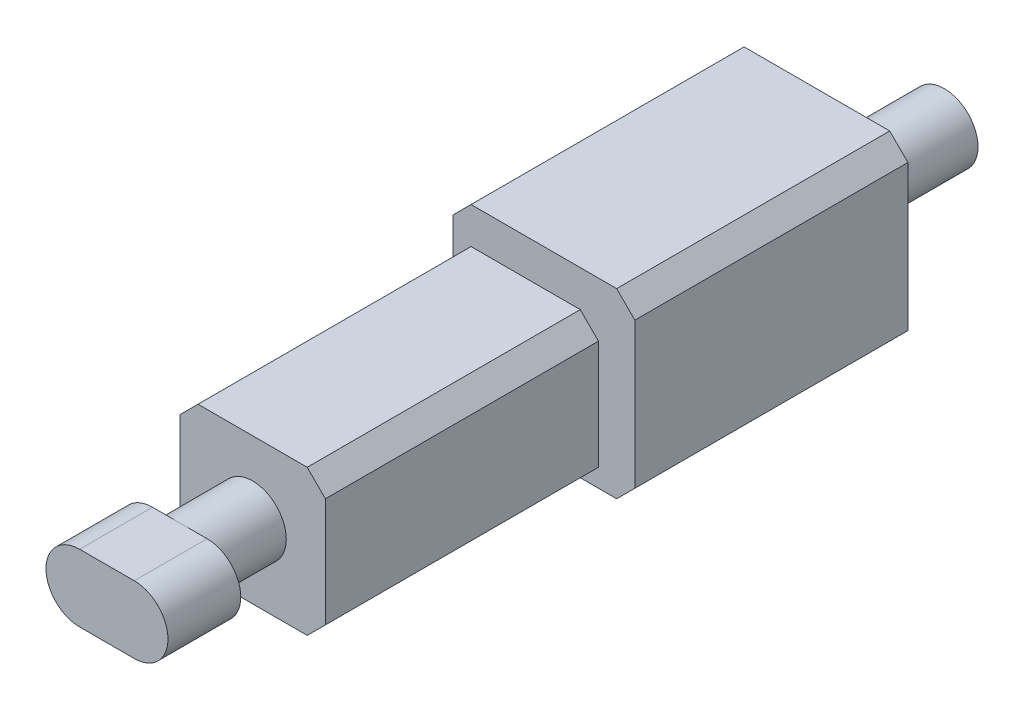
from build123d import *

# Parameters (mm, degrees)
SKETCH1_W           = 4
SKETCH1_H           = 15
BOSS_EXTRUDE1_DEPTH = 4
SKETCH2_R           = 0.925
BOSS_EXTRUDE2_DEPTH = 2
BOSS_EXTRUDE3_DEPTH = 2
SKETCH6_W           = 5
SKETCH6_H           = 5
BOSS_EXTRUDE5_DEPTH = 7.5
SKETCH7_R           = 0.925
BOSS_EXTRUDE6_DEPTH = 18
CHAMFER1_SIZE       = 0.5


with BuildPart() as part:
    # Sketch1 → Boss-Extrude1 (new body)
    with BuildSketch(Plane(origin=(0, 0, 0), x_dir=(1, 0, 0), z_dir=(0, 1, 0))):
        Rectangle(SKETCH1_W, SKETCH1_H)
    extrude(amount=BOSS_EXTRUDE1_DEPTH)

    # Sketch2 → Boss-Extrude2 (add)
    with BuildSketch(Plane.XY.offset(7.5)):
        with Locations((0, 2)):
            Circle(SKETCH2_R)
    extrude(amount=BOSS_EXTRUDE2_DEPTH)

    # Sketch3 → Boss-Extrude3 (add)
    with BuildSketch(Plane.XY.offset(9.5)):
        with BuildLine():
            Line((-0.75, 2.925), (0.75, 2.925))
            ThreePointArc((0.75, 2.925), (1.675, 2), (0.75, 1.075))
            Line((0.75, 1.075), (-0.75, 1.075))
            ThreePointArc((-0.75, 1.075), (-1.675, 2), (-0.75, 2.925))
        make_face()
    extrude(amount=BOSS_EXTRUDE3_DEPTH)

    # Sketch6 → Boss-Extrude5 (add)
    with BuildSketch(Plane.XY):
        with Locations((0.5, 2.5)):
            Rectangle(SKETCH6_W, SKETCH6_H)
    extrude(amount=-BOSS_EXTRUDE5_DEPTH)

    # Sketch7 → Boss-Extrude6 (add)
    with BuildSketch(Plane.XY.offset(7.5)):
        with Locations((1, 2.832903413)):
            Circle(SKETCH7_R)
    extrude(amount=-BOSS_EXTRUDE6_DEPTH)

    # Chamfer1
    chamfer1_edges = [part.edges().sort_by_distance(p)[0] for p in [
        (-2, 4, 3.75),
        (3, 0, -3.75),
        (-2, 5, -3.75),
        (3, 5, -3.75),
        (2, 4, 3.75),
        (-2, 0, 0),
        (2, 0, 3.75),
    ]]
    chamfer(chamfer1_edges, length=CHAMFER1_SIZE)


solid = part.part
